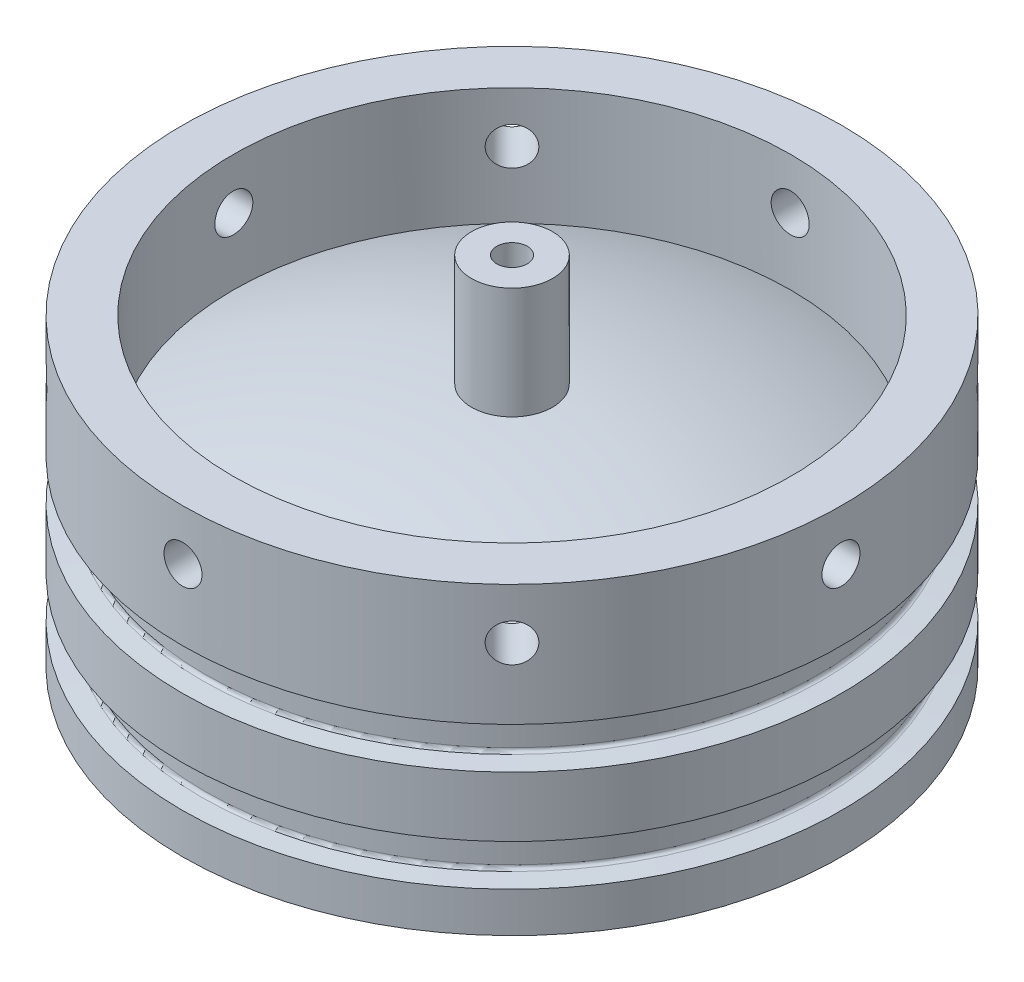
from build123d import *

# Parameters (mm, degrees)
LPATTERN1_COUNT                     = 2
LPATTERN1_PITCH                     = 12.7
F_3_16_0_1875_DIAMETER_HOLE1_REACH  = 99.602
F_3_16_0_1875_DIAMETER_HOLE1_BORE_R = 2.38125
CIRPATTERN1_COUNT                   = 8


with BuildPart() as part:
    # Sketch1 → Revolve1 (revolve)
    with BuildSketch(Plane.XY, mode=Mode.PRIVATE) as revolve1_sk:
        with BuildLine():
            Line((-41.275, 0), (-41.275, 38.1))
            Line((-41.275, 38.1), (-34.925, 38.1))
            Line((-34.925, 38.1), (-34.925, 23.387175559))
            ThreePointArc((-34.925, 23.387175559), (-20.331564533, 28.378185371), (-5.08, 30.673466828))
            Line((-5.08, 30.673466828), (-5.08, 44.643466828))
            Line((-5.08, 44.643466828), (-1.913255, 44.643466828))
            Line((-1.913255, 44.643466828), (-1.913255, 21.275094612))
            ThreePointArc((-1.913255, 21.275094612), (-11.635422449, 20.405538061), (-21.166666667, 18.300294093))
            ThreePointArc((-21.166666667, 18.300294093), (-31.101765087, 11.4476253), (-34.925, 0))
            Line((-34.925, 0), (-41.275, 0))
        make_face()
    revolve(revolve1_sk.sketch.rotate(Axis((0, -55, 0), (0, 1, 0)), 270), axis=Axis((0, -55, 0), (0, 1, 0)))

    # Sketch3 → Groove for AS 568-234_ O-Ring1 (revolve, cut)
    with BuildSketch(Plane(origin=(0, -55, 0), x_dir=(0, 0, -1), z_dir=(-1, 0, 0)), mode=Mode.PRIVATE) as groove_for_as_568_234_o_ring1_sk:
        with BuildLine():
            Line((38.861359272, -60.2451), (41.3639, -60.026156056))
            Line((41.3639, -60.026156056), (41.3639, -65.213843944))
            Line((41.3639, -65.213843944), (38.861359272, -64.9949))
            ThreePointArc((38.861359272, -64.9949), (38.572380224, -64.852391304), (38.4556, -64.552091457))
            Line((38.4556, -64.552091457), (38.4556, -60.687908543))
            ThreePointArc((38.4556, -60.687908543), (38.572380224, -60.387608696), (38.861359272, -60.2451))
        make_face()
    groove_for_as_568_234_o_ring1 = revolve(groove_for_as_568_234_o_ring1_sk.sketch.rotate(Axis((0, -105, 0), (0, 1, 0)), 90), axis=Axis((0, -105, 0), (0, 1, 0)), mode=Mode.SUBTRACT)

    # LPattern1: Groove for AS 568-234_ O-Ring1 ×2
    with Locations(*[(0, i * LPATTERN1_PITCH, 0) for i in range(1, LPATTERN1_COUNT)]):
        add(groove_for_as_568_234_o_ring1, mode=Mode.SUBTRACT)

    # 3_16 _0.1875_ Diameter Hole1 bore (on position points) → 3_16 _0.1875_ Diameter Hole1 (cut, up to next)
    with BuildSketch(Plane(origin=(0, 31.75, 41.275), x_dir=(1, 0, 0), z_dir=(0, 0, 1)), mode=Mode.PRIVATE) as f_3_16_0_1875_diameter_hole1_sk1:
        Circle(F_3_16_0_1875_DIAMETER_HOLE1_BORE_R)
    f_3_16_0_1875_diameter_hole1_tool1 = extrude(f_3_16_0_1875_diameter_hole1_sk1.sketch, amount=-F_3_16_0_1875_DIAMETER_HOLE1_REACH, mode=Mode.PRIVATE) & part.part
    f_3_16_0_1875_diameter_hole1 = f_3_16_0_1875_diameter_hole1_tool1.solids().sort_by_distance((0, 31.75, 41.275))[0]
    add(f_3_16_0_1875_diameter_hole1, mode=Mode.SUBTRACT)

    # CirPattern1: 3_16 _0.1875_ Diameter Hole1 ×8 about axis
    cirpattern1_axis = Axis((0, -55, 0), (0, 1, 0))
    for i in range(1, CIRPATTERN1_COUNT):
        add(f_3_16_0_1875_diameter_hole1.rotate(cirpattern1_axis, i * 360 / CIRPATTERN1_COUNT), mode=Mode.SUBTRACT)


solid = part.part
